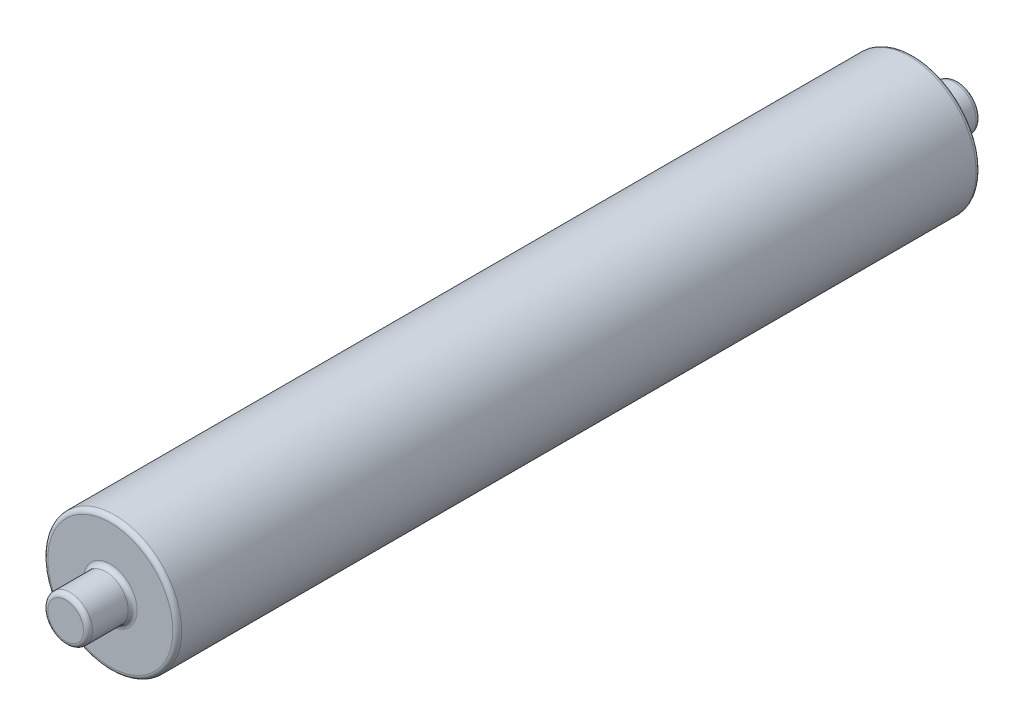
from build123d import *

# Parameters (mm, degrees)
SKETCH1_R           = 38.1
BOSS_EXTRUDE1_DEPTH = 457.2
SKETCH2_R           = 12.7
BOSS_EXTRUDE2_DEPTH = 25.4
SKETCH3_R           = 12.7
BOSS_EXTRUDE3_DEPTH = 25.4
FILLET1_R           = 2.54
FILLET2_R           = 2.54


with BuildPart() as part:
    # Sketch1 → Boss-Extrude1 (new body)
    with BuildSketch(Plane.XY):
        Circle(SKETCH1_R)
    extrude(amount=BOSS_EXTRUDE1_DEPTH)

    # Sketch2 → Boss-Extrude2 (add)
    with BuildSketch(Plane(origin=(0, 0, 0), x_dir=(-1, 0, 0), z_dir=(0, 0, -1))):
        Circle(SKETCH2_R)
    extrude(amount=BOSS_EXTRUDE2_DEPTH)

    # Sketch3 → Boss-Extrude3 (add)
    with BuildSketch(Plane.XY.offset(457.2)):
        Circle(SKETCH3_R)
    extrude(amount=BOSS_EXTRUDE3_DEPTH)

    # Fillet1
    fillet1_edges = [part.edges().sort_by_distance(p)[0] for p in [
        (-12.7, 0, 457.2),
        (12.7, 0, 0),
    ]]
    fillet(fillet1_edges, radius=FILLET1_R)

    # Fillet2
    fillet2_edges = [part.edges().sort_by_distance(p)[0] for p in [
        (-12.7, 0, 482.6),
        (-38.1, 0, 0),
        (-38.1, 0, 457.2),
        (12.7, 0, -25.4),
    ]]
    fillet(fillet2_edges, radius=FILLET2_R)


solid = part.part
